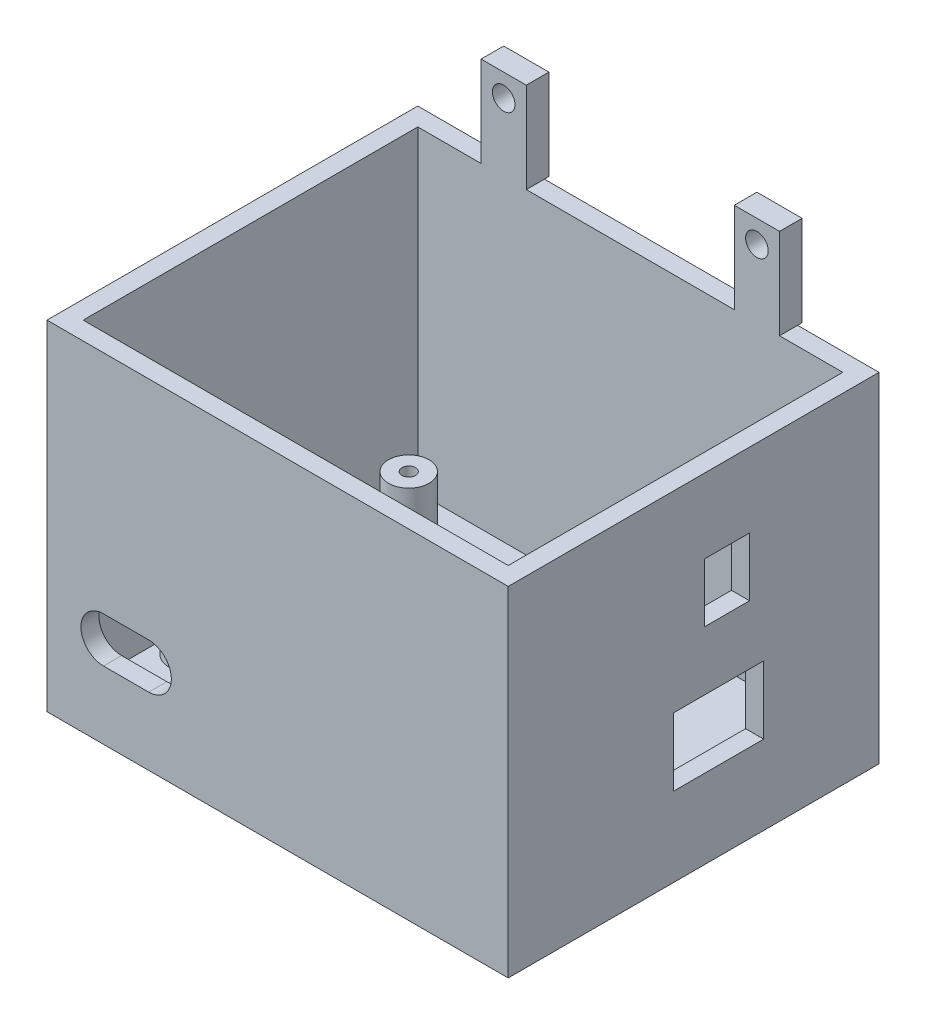
from build123d import *

# Parameters (mm, degrees)
SKETCH1_W           = 102
SKETCH1_H           = 82
BOSS_EXTRUDE1_DEPTH = 5
SKETCH2_W           = 102
SKETCH2_H           = 82
SKETCH2_W_2         = 94
SKETCH2_H_2         = 74
BOSS_EXTRUDE2_DEPTH = 70
CUT_EXTRUDE1_REACH  = 84
SKETCH9_W           = 20
SKETCH9_H           = 15
SKETCH9_W_2         = 10
SKETCH9_H_2         = 13
CUT_EXTRUDE7_DEPTH  = 10
SKETCH10_R          = 5
SKETCH10_R_2        = 4.5
BOSS_EXTRUDE5_DEPTH = 10
SKETCH11_R          = 1.5
CUT_EXTRUDE8_DEPTH  = 10
SKETCH13_W          = 10
SKETCH13_H          = 5
BOSS_EXTRUDE6_DEPTH = 20
SKETCH14_R          = 2.5
CUT_EXTRUDE9_DEPTH  = 10


with BuildPart() as part:
    # Sketch1 → Boss-Extrude1 (new body)
    with BuildSketch(Plane(origin=(0, 0, 0), x_dir=(1, 0, 0), z_dir=(0, 1, 0))):
        Rectangle(SKETCH1_W, SKETCH1_H)
    extrude(amount=BOSS_EXTRUDE1_DEPTH)

    # Sketch2 → Boss-Extrude2 (add)
    with BuildSketch(Plane(origin=(0, 5, 0), x_dir=(1, 0, 0), z_dir=(0, 1, 0))):
        Rectangle(SKETCH2_W, SKETCH2_H)
        Rectangle(SKETCH2_W_2, SKETCH2_H_2, mode=Mode.SUBTRACT)
    extrude(amount=BOSS_EXTRUDE2_DEPTH)

    # Sketch4 → Cut-Extrude1 (cut, up to next)
    with BuildSketch(Plane.XY.offset(41), mode=Mode.PRIVATE) as cut_extrude1_sk1:
        with BuildLine():
            Line((-38.5, 25), (-28.5, 25))
            ThreePointArc((-28.5, 25), (-23.5, 20), (-28.5, 15))
            Line((-28.5, 15), (-38.5, 15))
            ThreePointArc((-38.5, 15), (-43.5, 20), (-38.5, 25))
        make_face()
    cut_extrude1_tool1 = extrude(cut_extrude1_sk1.sketch, amount=-CUT_EXTRUDE1_REACH, mode=Mode.PRIVATE) & part.part
    add(cut_extrude1_tool1.solids().sort_by_distance((-33.5, 20, 41))[0], mode=Mode.SUBTRACT)

    # Sketch9 → Cut-Extrude7 (cut)
    with BuildSketch(Plane(origin=(51, 0, 0), x_dir=(0, 0, -1), z_dir=(1, 0, 0))):
        with Locations((5.5, 25)):
            Rectangle(SKETCH9_W, SKETCH9_H)
        with Locations((7.375245753, 52.06044871)):
            Rectangle(SKETCH9_W_2, SKETCH9_H_2)
    extrude(amount=-CUT_EXTRUDE7_DEPTH, mode=Mode.SUBTRACT)

    # Sketch10 → Boss-Extrude5 (add)
    with BuildSketch(Plane(origin=(0, 5, 0), x_dir=(1, 0, 0), z_dir=(0, 1, 0))):
        with Locations((17, -20)):
            Circle(SKETCH10_R)
        with Locations((-40.991198651, -18.989614408)):
            Circle(SKETCH10_R)
        with Locations((15.99137867, 29)):
            Circle(SKETCH10_R)
        with Locations((-42, 30)):
            Circle(SKETCH10_R_2)
    extrude(amount=BOSS_EXTRUDE5_DEPTH)

    # Sketch11 → Cut-Extrude8 (cut)
    with BuildSketch(Plane(origin=(0, 5, 0), x_dir=(1, 0, 0), z_dir=(0, 1, 0))):
        with Locations((-42, 30)):
            Circle(SKETCH11_R)
        with Locations((15.99137867, 29)):
            Circle(SKETCH11_R)
        with Locations((-40.991198651, -18.989614408)):
            Circle(SKETCH11_R)
        with Locations((17, -20)):
            Circle(SKETCH11_R)
    extrude(amount=CUT_EXTRUDE8_DEPTH, mode=Mode.SUBTRACT)

    # Sketch13 → Boss-Extrude6 (add)
    with BuildSketch(Plane(origin=(0, 75, 0), x_dir=(1, 0, 0), z_dir=(0, 1, 0))):
        with Locations((-28, 39.5)):
            Rectangle(SKETCH13_W, SKETCH13_H)
        with Locations((28, 39.5)):
            Rectangle(SKETCH13_W, SKETCH13_H)
    extrude(amount=BOSS_EXTRUDE6_DEPTH)

    # Sketch14 → Cut-Extrude9 (cut)
    with BuildSketch(Plane.XY.offset(-37)):
        with Locations((-28, 90)):
            Circle(SKETCH14_R)
        with Locations((28, 90)):
            Circle(SKETCH14_R)
    extrude(amount=-CUT_EXTRUDE9_DEPTH, mode=Mode.SUBTRACT)


solid = part.part
